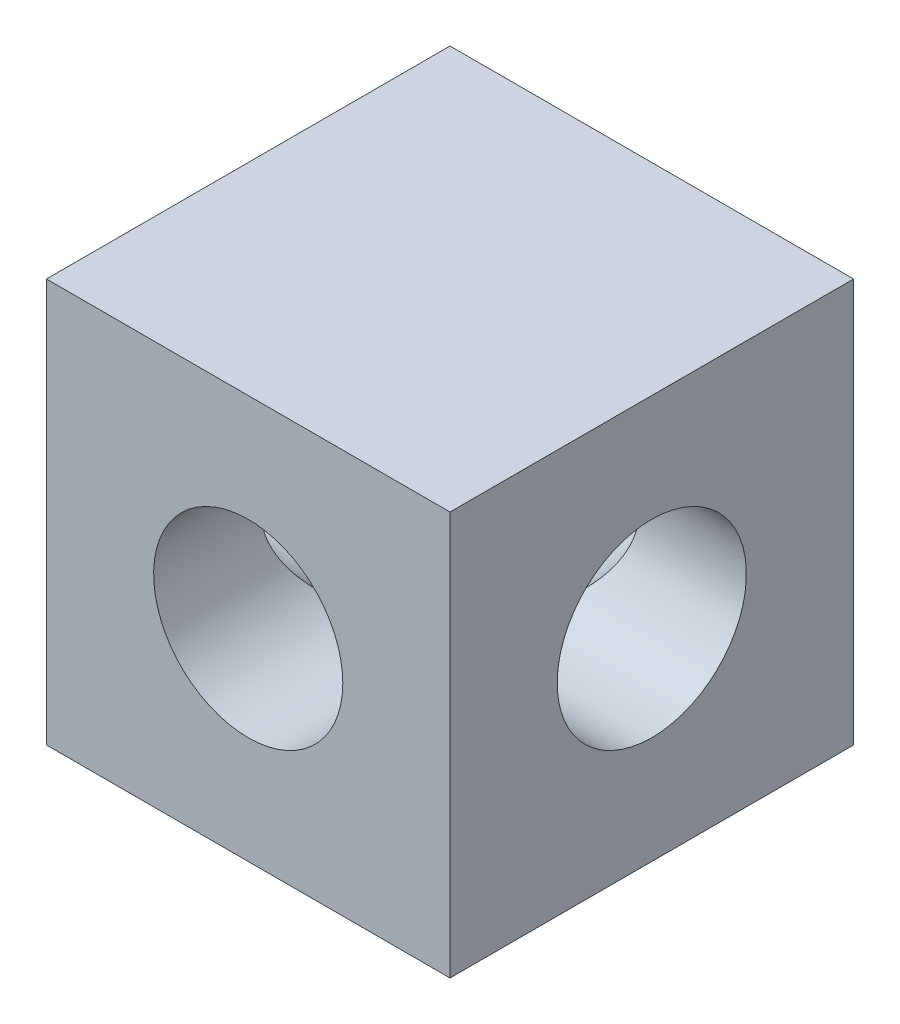
from build123d import *

# Parameters (mm, degrees)
SKETCH1_W          = 20.32
SKETCH1_H          = 20.32
SKETCH1_R          = 4.7625
BASE_EXTRUDE_DEPTH = 20.32
SKETCH3_R          = 4.7625
CUT_EXTRUDE1_DEPTH = 21.32


with BuildPart() as part:
    # Sketch1 → Base-Extrude (new body)
    with BuildSketch(Plane.XY):
        with Locations((-16.978268156, 8.535251397)):
            Rectangle(SKETCH1_W, SKETCH1_H)
        with Locations((-16.978268156, 8.535251397)):
            Circle(SKETCH1_R, mode=Mode.SUBTRACT)
    extrude(amount=BASE_EXTRUDE_DEPTH)

    # Sketch3 → Cut-Extrude1 (cut, through all)
    with BuildSketch(Plane(origin=(-6.818268156, 0, 0), x_dir=(0, 0, -1), z_dir=(1, 0, 0))):
        with Locations((-10.16, 8.535251397)):
            Circle(SKETCH3_R)
    extrude(amount=-CUT_EXTRUDE1_DEPTH, mode=Mode.SUBTRACT)


solid = part.part
